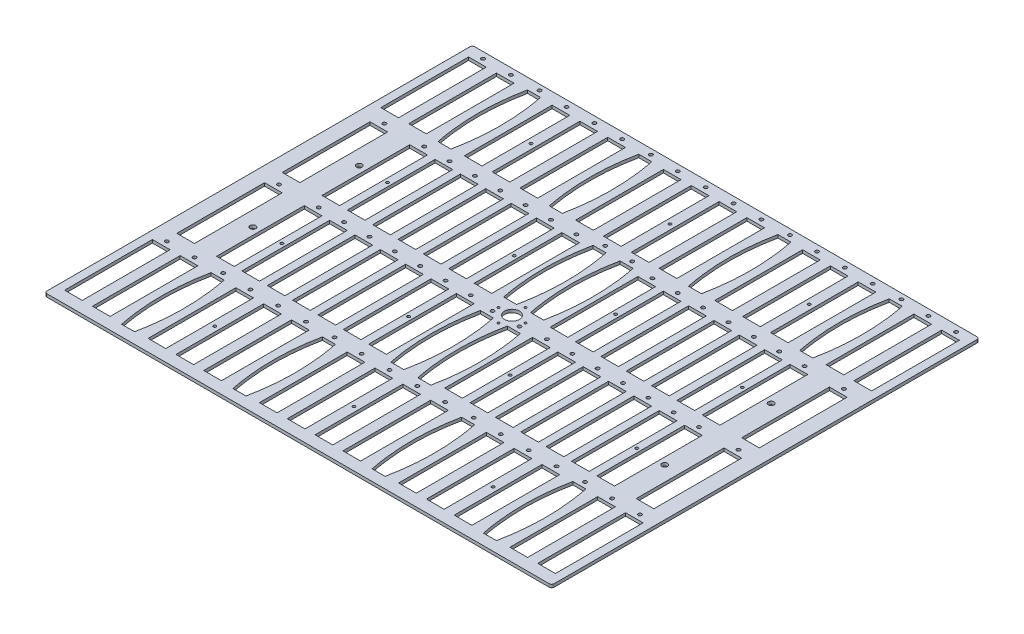
from build123d import *

# Parameters (mm, degrees)
SKETCH1_W                  = 525.4625
SKETCH1_H                  = 443.27572
BOSS_EXTRUDE1_DEPTH        = 3.175
SKETCH2_R                  = 7.62
CUT_EXTRUDE1_DEPTH         = 4.175
F_2_CLEARANCE_HOLE1_D      = 2.4384
F_1_0_228_DIAMETER_HOLE1_D = 5.7912
SKETCH5_R                  = 1.8288
SKETCH5_W                  = 18.288
SKETCH5_H                  = 90.932
CUT_EXTRUDE3_DEPTH         = 3.175
F_6_CLEARANCE_HOLE2_D      = 3.6576
SKETCH11_R                 = 1.8288
SKETCH11_W                 = 18.288
SKETCH11_H                 = 90.932
CUT_EXTRUDE5_DEPTH         = 3.175
SKETCH12_R                 = 1.8288
SKETCH12_W                 = 18.288
SKETCH12_H                 = 90.932
CUT_EXTRUDE6_DEPTH         = 3.175
FILLET1_R                  = 2.54
F_4_CLEARANCE_HOLE1_D      = 2.9464


with BuildPart() as part:
    # Sketch1 → Boss-Extrude1 (new body)
    with BuildSketch(Plane(origin=(0, 0, 0), x_dir=(1, 0, 0), z_dir=(0, 1, 0))):
        Rectangle(SKETCH1_W, SKETCH1_H)
    extrude(amount=BOSS_EXTRUDE1_DEPTH)

    # Sketch2 → Cut-Extrude1 (cut, through all)
    with BuildSketch(Plane(origin=(0, 3.175, 0), x_dir=(1, 0, 0), z_dir=(0, 1, 0))):
        Circle(SKETCH2_R)
    extrude(amount=-CUT_EXTRUDE1_DEPTH, mode=Mode.SUBTRACT)

    # #2 Clearance Hole1 (through all)
    with Locations(Plane(origin=(0, 3.175, 0), x_dir=(1, 0, 0), z_dir=(0, 1, 0))):
        with Locations((0, 0), (0, 13.97), (13.97, 0), (0, -13.97), (-13.97, 0)):
            Hole(F_2_CLEARANCE_HOLE1_D / 2)

    # #1 (0.228) Diameter Hole1 (through all)
    with Locations(Plane(origin=(0, 3.175, 0), x_dir=(1, 0, 0), z_dir=(0, 1, 0))):
        with Locations((213.36, 55.1010709), (-213.36, -55.1010709), (-213.36, 55.1010709), (213.36, -55.1010709)):
            Hole(F_1_0_228_DIAMETER_HOLE1_D / 2)

    # Sketch5 → Cut-Extrude3 (cut)
    with BuildSketch(Plane(origin=(0, 3.175, 0), x_dir=(1, 0, 0), z_dir=(0, 1, 0))):
        with Locations((-245.13667, 215.13546)):
            Circle(SKETCH5_R)
        with Locations((-245.13667, -112.52708)):
            Circle(SKETCH5_R)
        with Locations((-216.29751, 215.13546)):
            Circle(SKETCH5_R)
        with Locations((-216.29751, -112.52708)):
            Circle(SKETCH5_R)
        with Locations((-187.457503333, 216.02446)):
            Circle(SKETCH5_R)
        with Locations((-72.09917, 216.02446)):
            Circle(SKETCH5_R)
        with Locations((-158.61919, 215.13546)):
            Circle(SKETCH5_R)
        with Locations((-158.61919, -112.52708)):
            Circle(SKETCH5_R)
        with Locations((-129.78003, 215.13546)):
            Circle(SKETCH5_R)
        with Locations((-129.78003, -112.52708)):
            Circle(SKETCH5_R)
        with Locations((-100.94087, 215.13546)):
            Circle(SKETCH5_R)
        with Locations((-100.94087, -112.52708)):
            Circle(SKETCH5_R)
        with Locations((72.098746667, 216.02446)):
            Circle(SKETCH5_R)
        with Locations((187.45708, 216.02446)):
            Circle(SKETCH5_R)
        with Locations((-43.26255, 215.13546)):
            Circle(SKETCH5_R)
        with Locations((-43.26255, -112.52708)):
            Circle(SKETCH5_R)
        with Locations((-14.42339, 215.13546)):
            Circle(SKETCH5_R)
        with Locations((-14.42339, -112.52708)):
            Circle(SKETCH5_R)
        with Locations((14.41577, 215.13546)):
            Circle(SKETCH5_R)
        with Locations((14.41577, -112.52708)):
            Circle(SKETCH5_R)
        with Locations((43.25493, 215.13546)):
            Circle(SKETCH5_R)
        with Locations((43.25493, -112.52708)):
            Circle(SKETCH5_R)
        with Locations((-187.457503333, -111.78794)):
            Circle(SKETCH5_R)
        with Locations((-72.09917, -111.78794)):
            Circle(SKETCH5_R)
        with Locations((100.93325, 215.13546)):
            Circle(SKETCH5_R)
        with Locations((100.93325, -112.52708)):
            Circle(SKETCH5_R)
        with Locations((129.77241, 215.13546)):
            Circle(SKETCH5_R)
        with Locations((129.77241, -112.52708)):
            Circle(SKETCH5_R)
        with Locations((158.61157, 215.13546)):
            Circle(SKETCH5_R)
        with Locations((158.61157, -112.52708)):
            Circle(SKETCH5_R)
        with Locations((187.45708, -111.78794)):
            Circle(SKETCH5_R)
        with Locations((72.098746667, -111.78794)):
            Circle(SKETCH5_R)
        with Locations((216.28989, 215.13546)):
            Circle(SKETCH5_R)
        with Locations((216.28989, -112.52708)):
            Circle(SKETCH5_R)
        with Locations((245.12905, 215.13546)):
            Circle(SKETCH5_R)
        with Locations((245.12905, -112.52708)):
            Circle(SKETCH5_R)
        with Locations((-216.29751, 163.82746)):
            Rectangle(SKETCH5_W, SKETCH5_H)
        with Locations((-245.13667, 163.82746)):
            Rectangle(SKETCH5_W, SKETCH5_H)
        with Locations((-245.13667, -163.83508)):
            Rectangle(SKETCH5_W, SKETCH5_H)
        with Locations((-216.29751, -163.83508)):
            Rectangle(SKETCH5_W, SKETCH5_H)
        with BuildLine():
            Line((-194.188503333, 210.18246), (-180.726503333, 210.18246))
            add(Edge.make_bspline(
                [(-180.726503333, 210.18246), (-171.328503333, 163.82746), (-180.726503333, 117.47246)],
                knots=[0, 0, 0, 1, 1, 1], degree=2))
            Line((-180.726503333, 117.47246), (-194.188503333, 117.47246))
            add(Edge.make_bspline(
                [(-194.188503333, 210.18246), (-203.586503333, 163.82746), (-194.188503333, 117.47246)],
                knots=[0, 0, 0, 1, 1, 1], degree=2))
        make_face()
        with BuildLine():
            Line((-78.83017, 210.18246), (-65.36817, 210.18246))
            add(Edge.make_bspline(
                [(-65.36817, 210.18246), (-55.97017, 163.82746), (-65.36817, 117.47246)],
                knots=[0, 0, 0, 1, 1, 1], degree=2))
            Line((-65.36817, 117.47246), (-78.83017, 117.47246))
            add(Edge.make_bspline(
                [(-78.83017, 210.18246), (-88.22817, 163.82746), (-78.83017, 117.47246)],
                knots=[0, 0, 0, 1, 1, 1], degree=2))
        make_face()
        with Locations((-158.61919, 163.82746)):
            Rectangle(SKETCH5_W, SKETCH5_H)
        with Locations((-158.61919, -163.83508)):
            Rectangle(SKETCH5_W, SKETCH5_H)
        with Locations((-129.78003, 163.82746)):
            Rectangle(SKETCH5_W, SKETCH5_H)
        with Locations((-129.78003, -163.83508)):
            Rectangle(SKETCH5_W, SKETCH5_H)
        with Locations((-100.94087, 163.82746)):
            Rectangle(SKETCH5_W, SKETCH5_H)
        with Locations((-100.94087, -163.83508)):
            Rectangle(SKETCH5_W, SKETCH5_H)
        with BuildLine():
            Line((65.367746667, 210.18246), (78.829746667, 210.18246))
            add(Edge.make_bspline(
                [(78.829746667, 210.18246), (88.227746667, 163.82746), (78.829746667, 117.47246)],
                knots=[0, 0, 0, 1, 1, 1], degree=2))
            Line((78.829746667, 117.47246), (65.367746667, 117.47246))
            add(Edge.make_bspline(
                [(65.367746667, 210.18246), (55.969746667, 163.82746), (65.367746667, 117.47246)],
                knots=[0, 0, 0, 1, 1, 1], degree=2))
        make_face()
        with BuildLine():
            Line((180.72608, 210.18246), (194.18808, 210.18246))
            add(Edge.make_bspline(
                [(194.18808, 210.18246), (203.58608, 163.82746), (194.18808, 117.47246)],
                knots=[0, 0, 0, 1, 1, 1], degree=2))
            Line((194.18808, 117.47246), (180.72608, 117.47246))
            add(Edge.make_bspline(
                [(180.72608, 210.18246), (171.32808, 163.82746), (180.72608, 117.47246)],
                knots=[0, 0, 0, 1, 1, 1], degree=2))
        make_face()
        with BuildLine():
            Line((-194.188503333, -117.62994), (-180.726503333, -117.62994))
            add(Edge.make_bspline(
                [(-180.726503333, -117.62994), (-171.328503333, -163.98494), (-180.726503333, -210.33994)],
                knots=[0, 0, 0, 1, 1, 1], degree=2))
            Line((-180.726503333, -210.33994), (-194.188503333, -210.33994))
            add(Edge.make_bspline(
                [(-194.188503333, -117.62994), (-203.586503333, -163.98494), (-194.188503333, -210.33994)],
                knots=[0, 0, 0, 1, 1, 1], degree=2))
        make_face()
        with BuildLine():
            Line((-78.83017, -117.62994), (-65.36817, -117.62994))
            add(Edge.make_bspline(
                [(-65.36817, -117.62994), (-55.97017, -163.98494), (-65.36817, -210.33994)],
                knots=[0, 0, 0, 1, 1, 1], degree=2))
            Line((-65.36817, -210.33994), (-78.83017, -210.33994))
            add(Edge.make_bspline(
                [(-78.83017, -117.62994), (-88.22817, -163.98494), (-78.83017, -210.33994)],
                knots=[0, 0, 0, 1, 1, 1], degree=2))
        make_face()
        with Locations((-43.26255, 163.82746)):
            Rectangle(SKETCH5_W, SKETCH5_H)
        with Locations((-43.26255, -163.83508)):
            Rectangle(SKETCH5_W, SKETCH5_H)
        with Locations((-14.42339, 163.82746)):
            Rectangle(SKETCH5_W, SKETCH5_H)
        with Locations((-14.42339, -163.83508)):
            Rectangle(SKETCH5_W, SKETCH5_H)
        with Locations((14.41577, 163.82746)):
            Rectangle(SKETCH5_W, SKETCH5_H)
        with Locations((14.41577, -163.83508)):
            Rectangle(SKETCH5_W, SKETCH5_H)
        with Locations((43.25493, 163.82746)):
            Rectangle(SKETCH5_W, SKETCH5_H)
        with Locations((43.25493, -163.83508)):
            Rectangle(SKETCH5_W, SKETCH5_H)
        with BuildLine():
            Line((180.72608, -117.62994), (194.18808, -117.62994))
            add(Edge.make_bspline(
                [(194.18808, -117.62994), (203.58608, -163.98494), (194.18808, -210.33994)],
                knots=[0, 0, 0, 1, 1, 1], degree=2))
            Line((194.18808, -210.33994), (180.72608, -210.33994))
            add(Edge.make_bspline(
                [(180.72608, -117.62994), (171.32808, -163.98494), (180.72608, -210.33994)],
                knots=[0, 0, 0, 1, 1, 1], degree=2))
        make_face()
        with BuildLine():
            Line((65.367746667, -210.33994), (78.829746667, -210.33994))
            add(Edge.make_bspline(
                [(78.829746667, -117.62994), (88.227746667, -163.98494), (78.829746667, -210.33994)],
                knots=[0, 0, 0, 1, 1, 1], degree=2))
            Line((78.829746667, -117.62994), (65.367746667, -117.62994))
            add(Edge.make_bspline(
                [(65.367746667, -117.62994), (55.969746667, -163.98494), (65.367746667, -210.33994)],
                knots=[0, 0, 0, 1, 1, 1], degree=2))
        make_face()
        with Locations((100.93325, 163.82746)):
            Rectangle(SKETCH5_W, SKETCH5_H)
        with Locations((100.93325, -163.83508)):
            Rectangle(SKETCH5_W, SKETCH5_H)
        with Locations((129.77241, 163.82746)):
            Rectangle(SKETCH5_W, SKETCH5_H)
        with Locations((129.77241, -163.83508)):
            Rectangle(SKETCH5_W, SKETCH5_H)
        with Locations((158.61157, 163.82746)):
            Rectangle(SKETCH5_W, SKETCH5_H)
        with Locations((158.61157, -163.83508)):
            Rectangle(SKETCH5_W, SKETCH5_H)
        with Locations((216.28989, 163.82746)):
            Rectangle(SKETCH5_W, SKETCH5_H)
        with Locations((216.28989, -163.83508)):
            Rectangle(SKETCH5_W, SKETCH5_H)
        with Locations((245.12905, 163.82746)):
            Rectangle(SKETCH5_W, SKETCH5_H)
        with Locations((245.12905, -163.83508)):
            Rectangle(SKETCH5_W, SKETCH5_H)
    extrude(amount=-CUT_EXTRUDE3_DEPTH, mode=Mode.SUBTRACT)

    # #6 Clearance Hole2 (through all)
    with Locations(Plane(origin=(0, 3.175, 0), x_dir=(1, 0, 0), z_dir=(0, 1, 0))):
        with Locations((-245.13667, 215.13546)):
            Hole(F_6_CLEARANCE_HOLE2_D / 2)

    # Sketch11 → Cut-Extrude5 (cut)
    with BuildSketch(Plane(origin=(0, 3.175, 0), x_dir=(1, 0, 0), z_dir=(0, 1, 0))):
        with Locations((-238.04499, 105.86466)):
            Circle(SKETCH11_R)
        with Locations((238.04499, 105.86466)):
            Circle(SKETCH11_R)
        with Locations((238.04499, -3.40614)):
            Circle(SKETCH11_R)
        with Locations((-238.04499, -3.40614)):
            Circle(SKETCH11_R)
        with Locations((-238.04499, 54.55666)):
            Rectangle(SKETCH11_W, SKETCH11_H)
        with Locations((238.04499, 54.55666)):
            Rectangle(SKETCH11_W, SKETCH11_H)
        with Locations((238.04499, -54.71414)):
            Rectangle(SKETCH11_W, SKETCH11_H)
        with Locations((-238.04499, -54.71414)):
            Rectangle(SKETCH11_W, SKETCH11_H)
    extrude(amount=-CUT_EXTRUDE5_DEPTH, mode=Mode.SUBTRACT)

    # Sketch12 → Cut-Extrude6 (cut)
    with BuildSketch(Plane(origin=(0, 3.175, 0), x_dir=(1, 0, 0), z_dir=(0, 1, 0))):
        with Locations((-196.85, 105.86466)):
            Circle(SKETCH12_R)
        with Locations((-170.576875, 105.86466)):
            Circle(SKETCH12_R)
        with Locations((-144.30375, 105.86466)):
            Circle(SKETCH12_R)
        with Locations((-118.030625, 105.86466)):
            Circle(SKETCH12_R)
        with Locations((-91.7575, 105.86466)):
            Circle(SKETCH12_R)
        with Locations((-65.484375, 105.86466)):
            Circle(SKETCH12_R)
        with Locations((-39.21125, 105.86466)):
            Circle(SKETCH12_R)
        with Locations((-13.97, 110.56366)):
            Circle(SKETCH12_R)
        with Locations((13.97, 110.56366)):
            Circle(SKETCH12_R)
        with Locations((39.608125, 105.86466)):
            Circle(SKETCH12_R)
        with Locations((65.88125, 105.86466)):
            Circle(SKETCH12_R)
        with Locations((92.154375, 105.86466)):
            Circle(SKETCH12_R)
        with Locations((118.4275, 105.86466)):
            Circle(SKETCH12_R)
        with Locations((144.700625, 105.86466)):
            Circle(SKETCH12_R)
        with Locations((170.97375, 105.86466)):
            Circle(SKETCH12_R)
        with Locations((197.246875, 105.86466)):
            Circle(SKETCH12_R)
        with Locations((-170.576875, -3.40614)):
            Circle(SKETCH12_R)
        with Locations((-144.30375, -3.40614)):
            Circle(SKETCH12_R)
        with Locations((-118.030625, -3.40614)):
            Circle(SKETCH12_R)
        with Locations((-91.7575, -3.40614)):
            Circle(SKETCH12_R)
        with Locations((-65.484375, -3.40614)):
            Circle(SKETCH12_R)
        with Locations((-39.21125, -3.40614)):
            Circle(SKETCH12_R)
        with Locations((13.97, -6.27634)):
            Circle(SKETCH12_R)
        with Locations((-13.97, -6.27634)):
            Circle(SKETCH12_R)
        with Locations((39.608125, -3.40614)):
            Circle(SKETCH12_R)
        with Locations((65.88125, -3.40614)):
            Circle(SKETCH12_R)
        with Locations((92.154375, -3.40614)):
            Circle(SKETCH12_R)
        with Locations((118.4275, -3.40614)):
            Circle(SKETCH12_R)
        with Locations((144.700625, -3.40614)):
            Circle(SKETCH12_R)
        with Locations((170.97375, -3.40614)):
            Circle(SKETCH12_R)
        with Locations((197.246875, -3.40614)):
            Circle(SKETCH12_R)
        with Locations((-196.85, -3.40614)):
            Circle(SKETCH12_R)
        with Locations((-196.85, 54.55666)):
            Rectangle(SKETCH12_W, SKETCH12_H)
        with Locations((-170.576875, 54.55666)):
            Rectangle(SKETCH12_W, SKETCH12_H)
        with Locations((-144.30375, 54.55666)):
            Rectangle(SKETCH12_W, SKETCH12_H)
        with Locations((-118.030625, 54.55666)):
            Rectangle(SKETCH12_W, SKETCH12_H)
        with Locations((-91.7575, 54.55666)):
            Rectangle(SKETCH12_W, SKETCH12_H)
        with Locations((-65.484375, 54.55666)):
            Rectangle(SKETCH12_W, SKETCH12_H)
        with Locations((-39.21125, 54.55666)):
            Rectangle(SKETCH12_W, SKETCH12_H)
        with BuildLine():
            Line((-7.239, 104.72166), (-20.701, 104.72166))
            add(Edge.make_bspline(
                [(-20.701, 104.72166), (-30.099, 58.36666), (-20.701, 12.01166)],
                knots=[0, 0, 0, 1, 1, 1], degree=2))
            Line((-20.701, 12.01166), (-7.239, 12.01166))
            add(Edge.make_bspline(
                [(-7.239, 104.72166), (2.159, 58.36666), (-7.239, 12.01166)],
                knots=[0, 0, 0, 1, 1, 1], degree=2))
        make_face()
        with Locations((39.608125, 54.55666)):
            Rectangle(SKETCH12_W, SKETCH12_H)
        with Locations((65.88125, 54.55666)):
            Rectangle(SKETCH12_W, SKETCH12_H)
        with Locations((92.154375, 54.55666)):
            Rectangle(SKETCH12_W, SKETCH12_H)
        with Locations((118.4275, 54.55666)):
            Rectangle(SKETCH12_W, SKETCH12_H)
        with Locations((144.700625, 54.55666)):
            Rectangle(SKETCH12_W, SKETCH12_H)
        with Locations((170.97375, 54.55666)):
            Rectangle(SKETCH12_W, SKETCH12_H)
        with Locations((197.246875, 54.55666)):
            Rectangle(SKETCH12_W, SKETCH12_H)
        with Locations((-170.576875, -54.71414)):
            Rectangle(SKETCH12_W, SKETCH12_H)
        with Locations((-144.30375, -54.71414)):
            Rectangle(SKETCH12_W, SKETCH12_H)
        with Locations((-118.030625, -54.71414)):
            Rectangle(SKETCH12_W, SKETCH12_H)
        with Locations((-91.7575, -54.71414)):
            Rectangle(SKETCH12_W, SKETCH12_H)
        with Locations((-65.484375, -54.71414)):
            Rectangle(SKETCH12_W, SKETCH12_H)
        with Locations((-39.21125, -54.71414)):
            Rectangle(SKETCH12_W, SKETCH12_H)
        with BuildLine():
            Line((7.239, 12.01166), (20.701, 12.01166))
            add(Edge.make_bspline(
                [(20.701, 104.72166), (30.099, 58.36666), (20.701, 12.01166)],
                knots=[0, 0, 0, 1, 1, 1], degree=2))
            Line((20.701, 104.72166), (7.239, 104.72166))
            add(Edge.make_bspline(
                [(7.239, 104.72166), (-2.159, 58.36666), (7.239, 12.01166)],
                knots=[0, 0, 0, 1, 1, 1], degree=2))
        make_face()
        with Locations((39.608125, -54.71414)):
            Rectangle(SKETCH12_W, SKETCH12_H)
        with Locations((65.88125, -54.71414)):
            Rectangle(SKETCH12_W, SKETCH12_H)
        with Locations((92.154375, -54.71414)):
            Rectangle(SKETCH12_W, SKETCH12_H)
        with Locations((118.4275, -54.71414)):
            Rectangle(SKETCH12_W, SKETCH12_H)
        with Locations((144.700625, -54.71414)):
            Rectangle(SKETCH12_W, SKETCH12_H)
        with Locations((170.97375, -54.71414)):
            Rectangle(SKETCH12_W, SKETCH12_H)
        with Locations((197.246875, -54.71414)):
            Rectangle(SKETCH12_W, SKETCH12_H)
        with Locations((-196.85, -54.71414)):
            Rectangle(SKETCH12_W, SKETCH12_H)
        with BuildLine():
            Line((-7.239, -12.11834), (-20.701, -12.11834))
            add(Edge.make_bspline(
                [(-20.701, -12.11834), (-30.099, -58.47334), (-20.701, -104.82834)],
                knots=[0, 0, 0, 1, 1, 1], degree=2))
            Line((-20.701, -104.82834), (-7.239, -104.82834))
            add(Edge.make_bspline(
                [(-7.239, -12.11834), (2.159, -58.47334), (-7.239, -104.82834)],
                knots=[0, 0, 0, 1, 1, 1], degree=2))
        make_face()
        with BuildLine():
            Line((7.239, -12.11834), (20.701, -12.11834))
            add(Edge.make_bspline(
                [(20.701, -12.11834), (30.099, -58.47334), (20.701, -104.82834)],
                knots=[0, 0, 0, 1, 1, 1], degree=2))
            Line((20.701, -104.82834), (7.239, -104.82834))
            add(Edge.make_bspline(
                [(7.239, -12.11834), (-2.159, -58.47334), (7.239, -104.82834)],
                knots=[0, 0, 0, 1, 1, 1], degree=2))
        make_face()
    extrude(amount=-CUT_EXTRUDE6_DEPTH, mode=Mode.SUBTRACT)

    # Fillet1
    fillet1_edges = [part.edges().sort_by_distance(p)[0] for p in [
        (262.73125, 1.5875, 221.63786),
        (-262.73125, 1.5875, 221.63786),
        (-262.73125, 1.5875, -221.63786),
        (262.73125, 1.5875, -221.63786),
    ]]
    fillet(fillet1_edges, radius=FILLET1_R)

    # #4 Clearance Hole1 (through all)
    with Locations(Plane(origin=(0, 3.175, 0), x_dir=(1, 0, 0), z_dir=(0, 1, 0))):
        with Locations((-144.19961, -163.83508), (-144.19961, 163.82746), (-0.00381, 163.82746), (144.19199, 163.82746), (184.1103125, 54.55666), (52.7446875, 54.55666), (-52.3478125, 54.55666), (-183.7134375, 54.55666), (-183.7134375, -54.71414), (-52.3478125, -54.71414), (52.7446875, -54.71414), (184.1103125, -54.71414), (144.19199, -163.83508), (-0.00381, -163.83508)):
            Hole(F_4_CLEARANCE_HOLE1_D / 2)


solid = part.part
